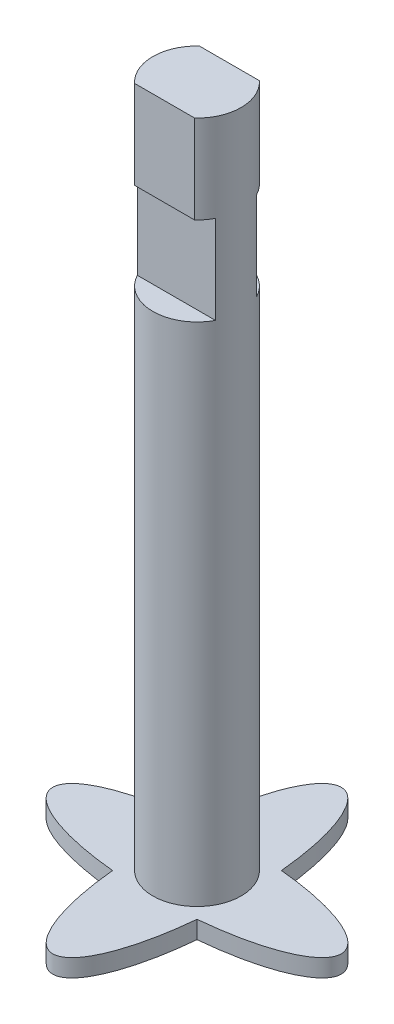
from build123d import *

# Parameters (mm, degrees)
SKETCH1_RX          = 12.25
SKETCH1_RY          = 3.75
BOSS_EXTRUDE1_DEPTH = 1.5
SKETCH2_R           = 3.75
BOSS_EXTRUDE2_DEPTH = 58
SKETCH3_W           = 7.5
SKETCH3_H           = 15
CUT_EXTRUDE1_DEPTH  = 1
SKETCH4_W           = 12.491636394
SKETCH4_H           = 7.5
CUT_EXTRUDE2_DEPTH  = 1
CIRPATTERN1_COUNT   = 2


with BuildPart() as part:
    # Sketch1 → Boss-Extrude1 (new body)
    with BuildSketch(Plane(origin=(0, 0, 0), x_dir=(1, 0, 0), z_dir=(0, 1, 0))):
        with Locations((0, 0)):
            Ellipse(SKETCH1_RX, SKETCH1_RY)
        with Locations(Location((0, 0), (0, 0, 90))):
            Ellipse(SKETCH1_RX, SKETCH1_RY)
    extrude(amount=BOSS_EXTRUDE1_DEPTH)

    # Sketch2 → Boss-Extrude2 (add)
    with BuildSketch(Plane(origin=(0, 1.5, 0), x_dir=(1, 0, 0), z_dir=(0, 1, 0))):
        Circle(SKETCH2_R)
    extrude(amount=BOSS_EXTRUDE2_DEPTH)

    # Sketch3 → Cut-Extrude1 (cut)
    with BuildSketch(Plane.XY.offset(3.75)):
        with Locations((0, 52)):
            Rectangle(SKETCH3_W, SKETCH3_H)
    cut_extrude1 = extrude(amount=-CUT_EXTRUDE1_DEPTH, mode=Mode.SUBTRACT)

    # Sketch4 → Cut-Extrude2 (cut)
    with BuildSketch(Plane.XY.offset(2.75)):
        with Locations((0.147803462, 48.25)):
            Rectangle(SKETCH4_W, SKETCH4_H)
    cut_extrude2 = extrude(amount=-CUT_EXTRUDE2_DEPTH, mode=Mode.SUBTRACT)

    # CirPattern1: Cut-Extrude1, Cut-Extrude2 ×2 about axis
    cirpattern1_axis = Axis((0, 59.5, 0), (0, 1, 0))
    for i in range(1, CIRPATTERN1_COUNT):
        add(cut_extrude1.rotate(cirpattern1_axis, i * 360 / CIRPATTERN1_COUNT), mode=Mode.SUBTRACT)
        add(cut_extrude2.rotate(cirpattern1_axis, i * 360 / CIRPATTERN1_COUNT), mode=Mode.SUBTRACT)


solid = part.part
